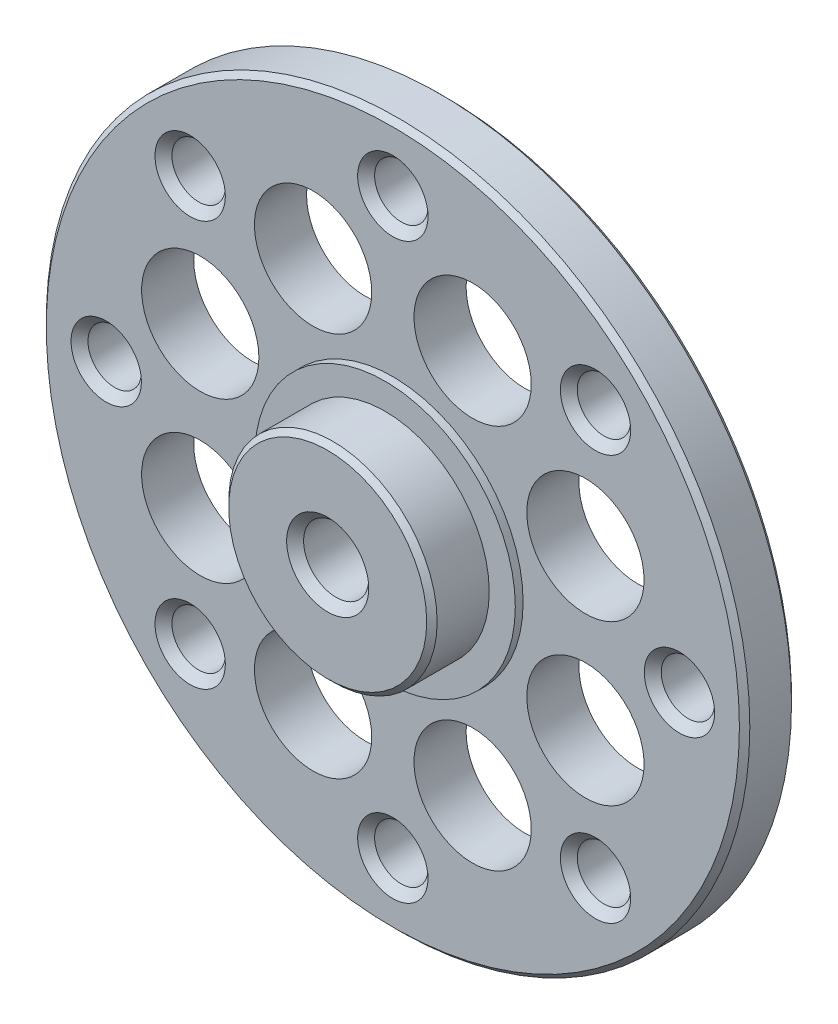
from build123d import *

# Parameters (mm, degrees)
SKETCH1_W                 = 13.5
SKETCH1_H                 = 2
SKETCH2_R                 = 5
BOSS_EXTRUDE1_DEPTH       = 0.3
SKETCH3_R                 = 4
BOSS_EXTRUDE2_DEPTH       = 2.2
SKETCH4_R                 = 5
BOSS_EXTRUDE3_DEPTH       = 0.5
F_8_CLEARANCE_HOLE1_D     = 4.5
F_8_CLEARANCE_HOLE1_DEPTH = 2.5
F_1_CLEARANCE_HOLE1_D     = 2.05
F_1_CLEARANCE_HOLE1_DEPTH = 2.5
F_2_CLEARANCE_HOLE1_D     = 2.5
F_2_CLEARANCE_HOLE1_DEPTH = 5
CHAMFER1_SIZE             = 0.325
CHAMFER2_SIZE2            = 0.200001177
CHAMFER2_SIZE             = 0.200001151
CHAMFER3_SIZE             = 0.2


with BuildPart() as part:
    # Sketch1 → Revolve1 (revolve)
    with BuildSketch(Plane(origin=(0, 0, 0), x_dir=(1, 0, 0), z_dir=(0, 1, 0))):
        with Locations((6.75, -1)):
            Rectangle(SKETCH1_W, SKETCH1_H)
    revolve(axis=Axis((0, 0, 0), (0, 0, 1)))

    # Sketch2 → Boss-Extrude1 (add)
    with BuildSketch(Plane.XY.offset(2)):
        Circle(SKETCH2_R)
    extrude(amount=BOSS_EXTRUDE1_DEPTH)

    # Sketch3 → Boss-Extrude2 (add)
    with BuildSketch(Plane.XY.offset(2.3)):
        Circle(SKETCH3_R)
    extrude(amount=BOSS_EXTRUDE2_DEPTH)

    # Sketch4 → Boss-Extrude3 (add)
    with BuildSketch(Plane(origin=(0, 0, 0), x_dir=(-1, 0, 0), z_dir=(0, 0, -1))):
        Circle(SKETCH4_R)
    extrude(amount=BOSS_EXTRUDE3_DEPTH)

    # #8 Clearance Hole1
    with Locations(Plane.XY.offset(2)):
        with Locations((3.061467459, 7.39103626), (7.39103626, 3.061467459), (7.39103626, -3.061467459), (3.061467459, -7.39103626), (-3.061467459, -7.39103626), (-7.39103626, -3.061467459), (-7.39103626, 3.061467459), (-3.061467459, 7.39103626)):
            Hole(F_8_CLEARANCE_HOLE1_D / 2, depth=F_8_CLEARANCE_HOLE1_DEPTH)

    # #1 Clearance Hole1
    with Locations(Plane.XY.offset(2)):
        with Locations((7.778174593, 7.778174593), (11, 0), (7.778174593, -7.778174593), (0, -11), (-7.778174593, -7.778174593), (-11, 0), (-7.778174593, 7.778174593), (0, 11)):
            Hole(F_1_CLEARANCE_HOLE1_D / 2, depth=F_1_CLEARANCE_HOLE1_DEPTH)

    # #2 Clearance Hole1
    with Locations(Plane.XY.offset(4.5)):
        with Locations((0, 0)):
            Hole(F_2_CLEARANCE_HOLE1_D / 2, depth=F_2_CLEARANCE_HOLE1_DEPTH)

    # Chamfer1
    chamfer1_edges = [part.edges().sort_by_distance(p)[0] for p in [
        (-6.753174593, -7.778174593, 2),
        (1.025, -11, 2),
        (8.803174593, -7.778174593, 2),
        (12.025, 0, 2),
        (8.803174593, 7.778174593, 2),
        (1.25, 0, 4.5),
        (1.025, 11, 2),
        (-6.753174593, 7.778174593, 2),
        (-9.975, 0, 2),
    ]]
    chamfer(chamfer1_edges, length=CHAMFER1_SIZE)

    # Chamfer2
    chamfer2_edges = [part.edges().sort_by_distance(p)[0] for p in [
        (-13.5, 0, 2),
        (-13.5, 0, 0),
    ]]
    chamfer(chamfer2_edges, length=CHAMFER2_SIZE, length2=CHAMFER2_SIZE2)

    # Chamfer3
    chamfer3_edges = [part.edges().sort_by_distance(p)[0] for p in [
        (-4, 0, 4.5),
        (5, 0, -0.5),
    ]]
    chamfer(chamfer3_edges, length=CHAMFER3_SIZE)


solid = part.part
